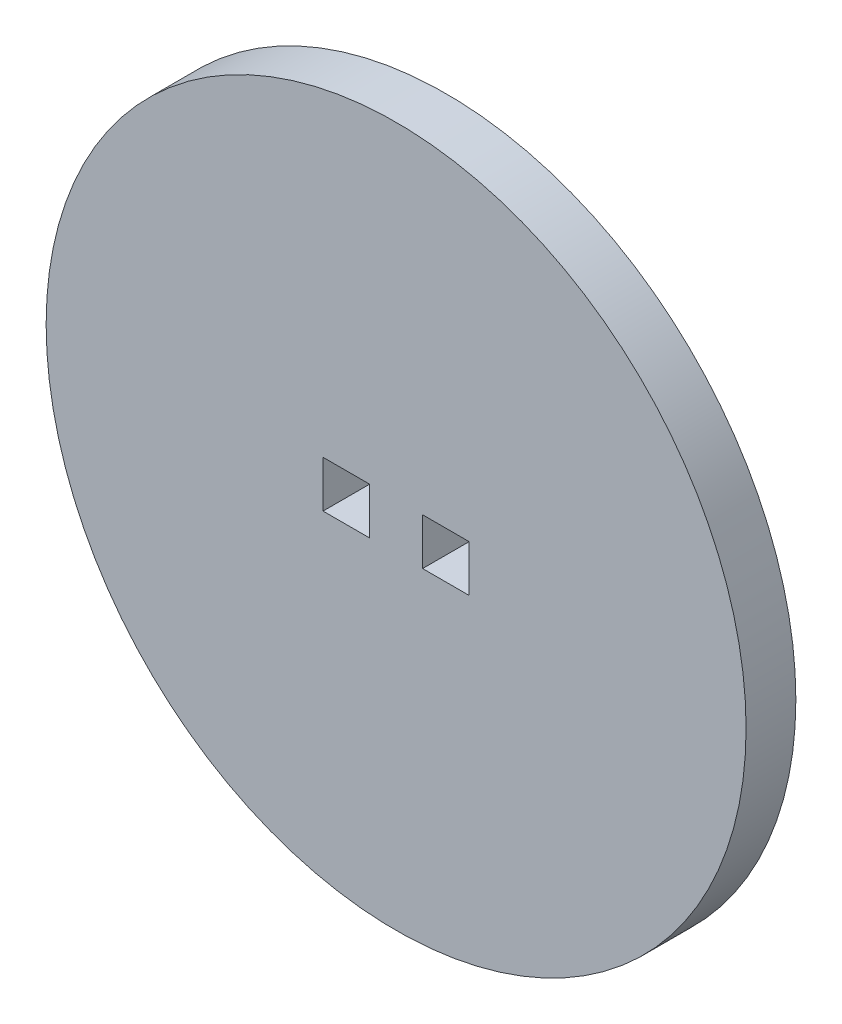
from build123d import *

# Parameters (mm, degrees)
SKETCH1_R           = 22.3266
SKETCH1_W           = 2.9718
SKETCH1_H           = 2.9718
BOSS_EXTRUDE1_DEPTH = 3.175


with BuildPart() as part:
    # Sketch1 → Boss-Extrude1 (new body)
    with BuildSketch(Plane.XY):
        Circle(SKETCH1_R)
        with Locations((-3.175, 0)):
            Rectangle(SKETCH1_W, SKETCH1_H, mode=Mode.SUBTRACT)
        with Locations((3.175, 0)):
            Rectangle(SKETCH1_W, SKETCH1_H, mode=Mode.SUBTRACT)
    extrude(amount=BOSS_EXTRUDE1_DEPTH)


solid = part.part
